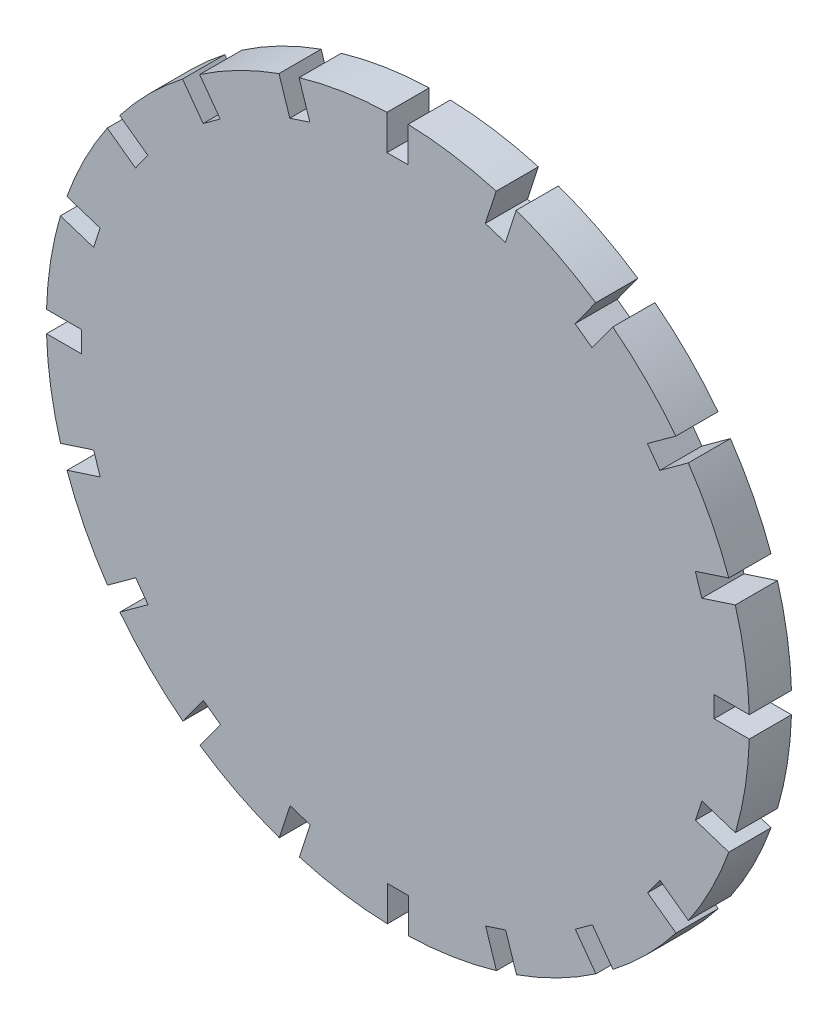
from build123d import *

# Parameters (mm, degrees)
SKETCH2_W           = 16
SKETCH2_H           = 6
SKETCH2_R           = 2.75
BOSS_EXTRUDE1_DEPTH = 6
SKETCH4_R           = 2.75
SKETCH4_W           = 16
SKETCH4_H           = 6
BOSS_EXTRUDE2_DEPTH = 6


with BuildPart() as part:
    # Sketch2 → Boss-Extrude1 (new body)
    with BuildSketch(Plane.XY):
        with BuildLine():
            ThreePointArc((-14.014958559, -48.70381072), (-7.820513245, -50.092784824), (-1.5, -50.685671098))
            Line((-1.5, -50.685671098), (-1.5, -45.708176163))
            Line((-1.5, -45.708176163), (1.5, -45.708176163))
            Line((1.5, -45.708176163), (1.5, -50.685671098))
            ThreePointArc((1.5, -50.685671098), (7.821643905, -50.09260576), (14.017156267, -48.703168924))
            Line((14.017156267, -48.703168924), (12.476730902, -43.962227135))
            Line((12.476730902, -43.962227135), (15.32990045, -43.035176152))
            Line((15.32990045, -43.035176152), (16.870328795, -47.776127109))
            ThreePointArc((16.870328795, -47.776127109), (22.700337229, -45.258088505), (28.164148211, -42.021379325))
            Line((28.164148211, -42.021379325), (25.229863981, -37.982683562))
            Line((25.229863981, -37.982683562), (27.656914964, -36.219327805))
            Line((27.656914964, -36.219327805), (30.591129228, -40.257927268))
            ThreePointArc((30.591129228, -40.257927268), (35.358240772, -36.060613271), (39.55477218, -31.292812793))
            Line((39.55477218, -31.292812793), (35.511033717, -28.354864828))
            Line((35.511033717, -28.354864828), (37.274389474, -25.927813845))
            Line((37.274389474, -25.927813845), (41.317825829, -28.865542317))
            ThreePointArc((41.317825829, -28.865542317), (44.554494815, -23.399517942), (47.071992795, -17.567224011))
            Line((47.071992795, -17.567224011), (42.313847582, -16.021208913))
            Line((42.313847582, -16.021208913), (43.240898565, -13.168039364))
            Line((43.240898565, -13.168039364), (47.998350807, -14.713829302))
            ThreePointArc((47.998350807, -14.713829302), (49.386863483, -8.514437454), (49.978066205, -2.189019992))
            Line((49.978066205, -2.189019992), (44.972398757, -2.189019992))
            Line((44.972398757, -2.189019992), (44.972398757, 0.810980008))
            Line((44.972398757, 0.810980008), (49.976916317, 0.810980008))
            ThreePointArc((49.976916317, 0.810980008), (49.380832331, 7.136146516), (47.987483994, 13.334664716))
            Line((47.987483994, 13.334664716), (43.22644973, 11.787710909))
            Line((43.22644973, 11.787710909), (42.299398746, 14.640880458))
            Line((42.299398746, 14.640880458), (47.058915168, 16.187341088))
            ThreePointArc((47.058915168, 16.187341088), (44.536626084, 22.0182168), (41.295318935, 27.482188044))
            Line((41.295318935, 27.482188044), (37.246906156, 24.540843989))
            Line((37.246906156, 24.540843989), (35.483550399, 26.967894972))
            Line((35.483550399, 26.967894972), (39.530326401, 29.908049839))
            ThreePointArc((39.530326401, 29.908049839), (35.329326435, 34.673156396), (30.558045552, 38.86714256))
            Line((30.558045552, 38.86714256), (27.619087422, 34.822013725))
            Line((27.619087422, 34.822013725), (25.192036439, 36.585369482))
            Line((25.192036439, 36.585369482), (28.129589934, 40.628565002))
            ThreePointArc((28.129589934, 40.628565002), (22.66202489, 43.861237429), (16.828745179, 46.374658668))
            Line((16.828745179, 46.374658668), (15.285431508, 41.62482759))
            Line((15.285431508, 41.62482759), (12.432261959, 42.551878573))
            Line((12.432261959, 42.551878573), (13.974753738, 47.299180128))
            ThreePointArc((13.974753738, 47.299180128), (7.776727495, 48.683346485), (1.453242586, 49.270700235))
            Line((1.453242586, 49.270700235), (1.453242586, 44.283378765))
            Line((1.453242586, 44.283378765), (-1.546757414, 44.283378765))
            Line((-1.546757414, 44.283378765), (-1.546757414, 49.2608737))
            ThreePointArc((-1.546757414, 49.2608737), (-7.866904098, 48.661958763), (-14.060191394, 47.266915506))
            Line((-14.060191394, 47.266915506), (-12.523488315, 42.537429737))
            Line((-12.523488315, 42.537429737), (-15.376657864, 41.610378754))
            Line((-15.376657864, 41.610378754), (-16.914659767, 46.343861891))
            ThreePointArc((-16.914659767, 46.343861891), (-22.740383136, 43.821308169), (-28.199510335, 40.580897657))
            Line((-28.199510335, 40.580897657), (-25.276621395, 36.557886164))
            Line((-25.276621395, 36.557886164), (-27.703672378, 34.794530407))
            Line((-27.703672378, 34.794530407), (-30.624981542, 38.815367524))
            ThreePointArc((-30.624981542, 38.815367524), (-35.385501758, 34.616974444), (-39.575762572, 29.849294558))
            Line((-39.575762572, 29.849294558), (-35.557791131, 26.93006743))
            Line((-35.557791131, 26.93006743), (-37.321146887, 24.503016447))
            Line((-37.321146887, 24.503016447), (-41.33714976, 27.420813327))
            ThreePointArc((-41.33714976, 27.420813327), (-44.567381262, 21.957845266), (-47.079571363, 16.129696634))
            Line((-47.079571363, 16.129696634), (-42.360604995, 14.596411515))
            Line((-42.360604995, 14.596411515), (-43.287655979, 11.743241967))
            Line((-43.287655979, 11.743241967), (-48.004645978, 13.275884924))
            ThreePointArc((-48.004645978, 13.275884924), (-49.389276358, 7.082804571), (-49.978315717, 0.764222594))
            Line((-49.978315717, 0.764222594), (-45.01915617, 0.764222594))
            Line((-45.01915617, 0.764222594), (-45.01915617, -2.235777406))
            Line((-45.01915617, -2.235777406), (-49.976658896, -2.235777406))
            ThreePointArc((-49.976658896, -2.235777406), (-49.380673152, -8.553500826), (-47.989286669, -14.744855434))
            Line((-47.989286669, -14.744855434), (-43.273207143, -13.212508307))
            Line((-43.273207143, -13.212508307), (-42.34615616, -16.065677856))
            Line((-42.34615616, -16.065677856), (-47.06108419, -17.597650839))
            ThreePointArc((-47.06108419, -17.597650839), (-44.542778803, -23.422507686), (-41.306963736, -28.881474636))
            Line((-41.306963736, -28.881474636), (-37.293663569, -25.965641387))
            Line((-37.293663569, -25.965641387), (-35.530307812, -28.39269237))
            Line((-35.530307812, -28.39269237), (-39.542974081, -31.308065065))
            ThreePointArc((-39.542974081, -31.308065065), (-35.348264075, -36.07058879), (-30.584062086, -40.263392586))
            Line((-30.584062086, -40.263392586), (-27.665844836, -36.246811123))
            Line((-27.665844836, -36.246811123), (-25.238793853, -38.01016688))
            Line((-25.238793853, -38.01016688), (-28.156765996, -42.026410983))
            ThreePointArc((-28.156765996, -42.026410983), (-22.695337069, -45.260635975), (-16.868173537, -47.776899552))
            Line((-16.868173537, -47.776899552), (-15.332188921, -43.049624988))
            Line((-15.332188921, -43.049624988), (-12.479019372, -43.976675971))
            Line((-12.479019372, -43.976675971), (-14.014958559, -48.70381072))
        make_face()
        with Locations((0, -31.708176163)):
            Rectangle(SKETCH2_W, SKETCH2_H, mode=Mode.SUBTRACT)
        with Locations((-17.5, -8.708176163)):
            Circle(SKETCH2_R, mode=Mode.SUBTRACT)
        with Locations((17.5, -8.708176163)):
            Circle(SKETCH2_R, mode=Mode.SUBTRACT)
    extrude(amount=BOSS_EXTRUDE1_DEPTH)

    # Sketch4 → Boss-Extrude2 (add)
    with BuildSketch(Plane(origin=(0, 0, 0), x_dir=(-1, 0, 0), z_dir=(0, 0, -1))):
        with Locations((17.5, -8.708176163)):
            Circle(SKETCH4_R)
        with Locations((-17.5, -8.708176163)):
            Circle(SKETCH4_R)
        with Locations((0, -31.708176163)):
            Rectangle(SKETCH4_W, SKETCH4_H)
    extrude(amount=-BOSS_EXTRUDE2_DEPTH)


solid = part.part
